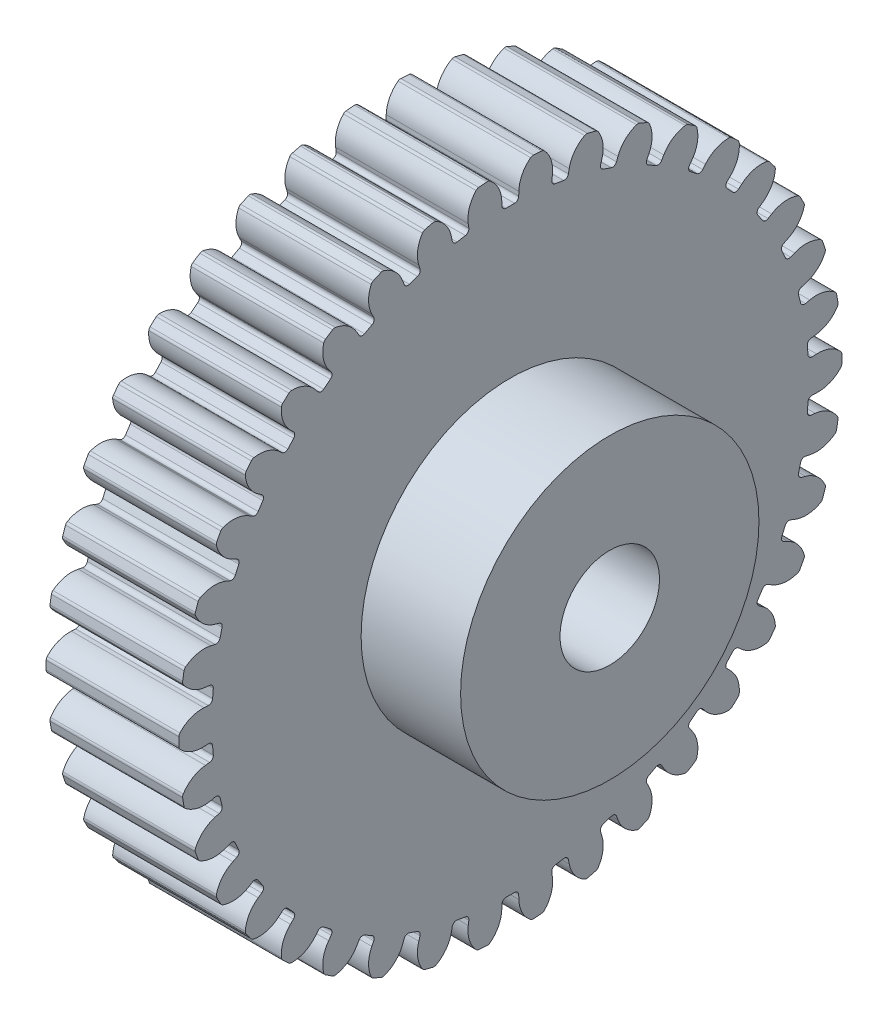
from build123d import *

# Parameters (mm, degrees)
ESQUISSE1_R                        = 20
ESQUISSE1_R_2                      = 3
EXTRUSION1_DEPTH                   = 8
ENL_V_MAT_EXTRU_2_DEPTH            = 8
CONG_2_R                           = 0.25
R_P_TITION_CIRCULAIRE1_COUNT       = 38
CONG_2_OF_R_P_TITION_CIRCULAIRE1_R = 0.25
ESQUISSE23_R                       = 9
ESQUISSE23_R_2                     = 3
EXTRUSION2_DEPTH                   = 6


with BuildPart() as part:
    # Esquisse1 → Extrusion1 (new body)
    with BuildSketch(Plane(origin=(0, 0, 0), x_dir=(0, 0, -1), z_dir=(1, 0, 0))):
        Circle(ESQUISSE1_R)
        Circle(ESQUISSE1_R_2, mode=Mode.SUBTRACT)
    extrude(amount=EXTRUSION1_DEPTH)

    # Esquisse22 → Enlèv. mat.-Extru.2 (cut)
    with BuildSketch(Plane.ZY):
        with BuildLine():
            Line((-0.5, 18), (0.5, 18))
            Line((0.5, 18), (0.513888889, 18.5))
            ThreePointArc((0.513888889, 18.5), (0.735252588, 19.32337007), (1.305341345, 19.957356638))
            ThreePointArc((1.305341345, 19.957356638), (0, 20), (-1.305341345, 19.957356638))
            ThreePointArc((-1.305341345, 19.957356638), (-0.735252588, 19.32337007), (-0.513888889, 18.5))
            Line((-0.513888889, 18.5), (-0.5, 18))
        make_face()
    enl_v_mat_extru_2 = extrude(amount=-ENL_V_MAT_EXTRU_2_DEPTH, mode=Mode.SUBTRACT)

    # Congé2
    cong_2_edges = [part.edges().sort_by_distance(p)[0] for p in [
        (4, 18, -0.5),
        (4, 19.957356638, -1.305341345),
        (4, 19.957356638, 1.305341345),
        (4, 18, 0.5),
    ]]
    fillet(cong_2_edges, radius=CONG_2_R)

    # Répétition circulaire1: Enlèv. mat.-Extru.2 ×38 about axis
    r_p_tition_circulaire1_axis = Axis((0, 0, 0), (1, 0, 0))
    for i in range(1, R_P_TITION_CIRCULAIRE1_COUNT):
        add(enl_v_mat_extru_2.rotate(r_p_tition_circulaire1_axis, i * 360 / R_P_TITION_CIRCULAIRE1_COUNT), mode=Mode.SUBTRACT)

    # Congé2 of Répétition circulaire1
    cong_2_of_r_p_tition_circulaire1_edges = [part.edges().sort_by_distance(p)[0] for p in [
        (4, 17.836800756, 2.469521973),
        (4, 19.90001643, 1.997334749),
        (4, 19.470312182, 4.572411129),
        (4, 17.672206166, 3.455883277),
        (4, 17.187060085, 5.371681825),
        (4, 19.299855649, 5.245528757),
        (4, 18.452168365, 7.714757457),
        (4, 16.862360616, 6.317499067),
        (4, 16.068501218, 8.127316199),
        (4, 18.173245117, 8.350638415),
        (4, 16.930697496, 10.646665313),
        (4, 15.592553825, 9.00678995),
        (4, 14.511635525, 10.661258574),
        (4, 16.550915832, 11.227964425),
        (4, 14.947401335, 13.288159892),
        (4, 13.897422813, 11.450399083),
        (4, 12.558930245, 12.904389606),
        (4, 14.477120708, 13.799020835),
        (4, 12.55637903, 15.56718811),
        (4, 11.823206334, 13.581671178),
        (4, 10.263650085, 14.79552253),
        (4, 12.008427471, 15.993675928),
        (4, 9.822851438, 17.421584016),
        (4, 9.426483607, 15.342470688),
        (4, 7.688404307, 16.283072167),
        (4, 9.212175635, 17.752065234),
        (4, 6.821382064, 18.800764525),
        (4, 6.77263098, 16.684767592),
        (4, 4.903438902, 17.326462043),
        (4, 6.164639663, 19.026224476),
        (4, 3.63384317, 19.667109188),
        (4, 3.934038636, 17.57194753),
        (4, 1.984720465, 17.897231201),
        (4, 2.948948391, 19.781397913),
        (4, 0.347182506, 19.996986381),
        (4, 0.988135972, 17.979810547),
        (4, -0.988135972, 17.979810547),
        (4, -0.347182506, 19.996986381),
        (4, -2.948948391, 19.781397913),
        (4, -1.984720465, 17.897231201),
        (4, -3.934038636, 17.57194753),
        (4, -3.63384317, 19.667109188),
        (4, -6.164639663, 19.026224476),
        (4, -4.903438902, 17.326462043),
        (4, -6.77263098, 16.684767592),
        (4, -6.821382064, 18.800764525),
        (4, -9.212175635, 17.752065234),
        (4, -7.688404307, 16.283072167),
        (4, -9.426483607, 15.342470688),
        (4, -9.822851438, 17.421584016),
        (4, -12.008427471, 15.993675928),
        (4, -10.263650085, 14.79552253),
        (4, -11.823206334, 13.581671178),
        (4, -12.55637903, 15.56718811),
        (4, -14.477120708, 13.799020835),
        (4, -12.558930245, 12.904389606),
        (4, -13.897422813, 11.450399083),
        (4, -14.947401335, 13.288159892),
        (4, -16.550915832, 11.227964425),
        (4, -14.511635525, 10.661258574),
        (4, -15.592553825, 9.00678995),
        (4, -16.930697496, 10.646665313),
        (4, -18.173245117, 8.350638415),
        (4, -16.068501218, 8.127316199),
        (4, -16.862360616, 6.317499067),
        (4, -18.452168365, 7.714757457),
        (4, -19.299855649, 5.245528757),
        (4, -17.187060085, 5.371681825),
        (4, -17.672206166, 3.455883277),
        (4, -19.470312182, 4.572411129),
        (4, -19.90001643, 1.997334749),
        (4, -17.836800756, 2.469521973),
        (4, -18, 0.5),
        (4, -19.957356638, 1.305341345),
        (4, -19.957356638, -1.305341345),
        (4, -18, -0.5),
        (4, -17.836800756, -2.469521973),
        (4, -19.90001643, -1.997334749),
        (4, -19.470312182, -4.572411129),
        (4, -17.672206166, -3.455883277),
        (4, -17.187060085, -5.371681825),
        (4, -19.299855649, -5.245528757),
        (4, -18.452168365, -7.714757457),
        (4, -16.862360616, -6.317499067),
        (4, -16.068501218, -8.127316199),
        (4, -18.173245117, -8.350638415),
        (4, -16.930697496, -10.646665313),
        (4, -15.592553825, -9.00678995),
        (4, -14.511635525, -10.661258574),
        (4, -16.550915832, -11.227964425),
        (4, -14.947401335, -13.288159892),
        (4, -13.897422813, -11.450399083),
        (4, -12.558930245, -12.904389606),
        (4, -14.477120708, -13.799020835),
        (4, -12.55637903, -15.56718811),
        (4, -11.823206334, -13.581671178),
        (4, -10.263650085, -14.79552253),
        (4, -12.008427471, -15.993675928),
        (4, -9.822851438, -17.421584016),
        (4, -9.426483607, -15.342470688),
        (4, -7.688404307, -16.283072167),
        (4, -9.212175635, -17.752065234),
        (4, -6.821382064, -18.800764525),
        (4, -6.77263098, -16.684767592),
        (4, -4.903438902, -17.326462043),
        (4, -6.164639663, -19.026224476),
        (4, -3.63384317, -19.667109188),
        (4, -3.934038636, -17.57194753),
        (4, -1.984720465, -17.897231201),
        (4, -2.948948391, -19.781397913),
        (4, -0.347182506, -19.996986381),
        (4, -0.988135972, -17.979810547),
        (4, 0.988135972, -17.979810547),
        (4, 0.347182506, -19.996986381),
        (4, 2.948948391, -19.781397913),
        (4, 1.984720465, -17.897231201),
        (4, 3.934038636, -17.57194753),
        (4, 3.63384317, -19.667109188),
        (4, 6.164639663, -19.026224476),
        (4, 4.903438902, -17.326462043),
        (4, 6.77263098, -16.684767592),
        (4, 6.821382064, -18.800764525),
        (4, 9.212175635, -17.752065234),
        (4, 7.688404307, -16.283072167),
        (4, 9.426483607, -15.342470688),
        (4, 9.822851438, -17.421584016),
        (4, 12.008427471, -15.993675928),
        (4, 10.263650085, -14.79552253),
        (4, 11.823206334, -13.581671178),
        (4, 12.55637903, -15.56718811),
        (4, 14.477120708, -13.799020835),
        (4, 12.558930245, -12.904389606),
        (4, 13.897422813, -11.450399083),
        (4, 14.947401335, -13.288159892),
        (4, 16.550915832, -11.227964425),
        (4, 14.511635525, -10.661258574),
        (4, 15.592553825, -9.00678995),
        (4, 16.930697496, -10.646665313),
        (4, 18.173245117, -8.350638415),
        (4, 16.068501218, -8.127316199),
        (4, 16.862360616, -6.317499067),
        (4, 18.452168365, -7.714757457),
        (4, 19.299855649, -5.245528757),
        (4, 17.187060085, -5.371681825),
        (4, 17.672206166, -3.455883277),
        (4, 19.470312182, -4.572411129),
        (4, 19.90001643, -1.997334749),
        (4, 17.836800756, -2.469521973),
    ]]
    fillet(cong_2_of_r_p_tition_circulaire1_edges, radius=CONG_2_OF_R_P_TITION_CIRCULAIRE1_R)

    # Esquisse23 → Extrusion2 (add)
    with BuildSketch(Plane(origin=(8, 0, 0), x_dir=(0, 0, -1), z_dir=(1, 0, 0))):
        Circle(ESQUISSE23_R)
        Circle(ESQUISSE23_R_2, mode=Mode.SUBTRACT)
    extrude(amount=EXTRUSION2_DEPTH)


solid = part.part
